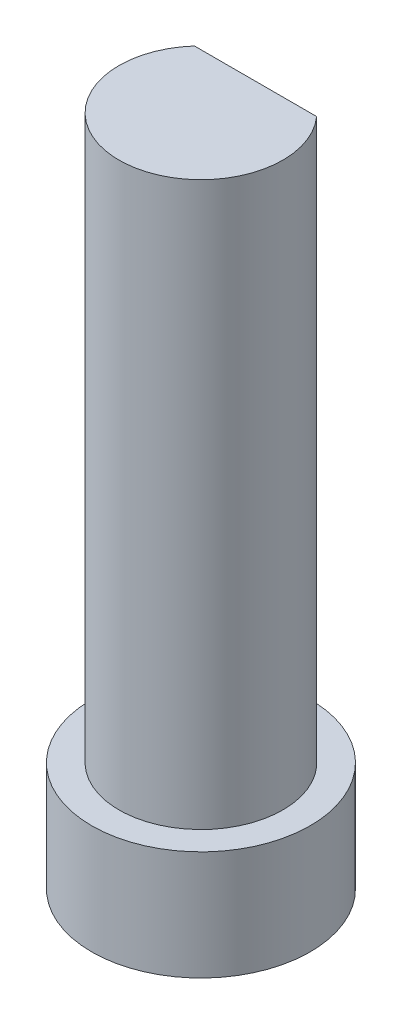
from build123d import *

# Parameters (mm, degrees)
CROQUIS1_R              = 2
SALIENTE_EXTRUIR1_DEPTH = 2
CROQUIS2_R              = 0.2
CORTAR_EXTRUIR1_DEPTH   = 2
CROQUIS3_R              = 1.5
SALIENTE_EXTRUIR2_DEPTH = 10.3
CORTAR_EXTRUIR2_DEPTH   = 10.3


with BuildPart() as part:
    # Croquis1 → Saliente-Extruir1 (new body)
    with BuildSketch(Plane(origin=(0, 0, 0), x_dir=(1, 0, 0), z_dir=(0, 1, 0))):
        Circle(CROQUIS1_R)
    extrude(amount=SALIENTE_EXTRUIR1_DEPTH)

    # Croquis2 → Cortar-Extruir1 (cut)
    with BuildSketch(Plane.XZ):
        Circle(CROQUIS2_R)
    extrude(amount=-CORTAR_EXTRUIR1_DEPTH, mode=Mode.SUBTRACT)


with BuildPart() as body_2:
    # Croquis3 → Saliente-Extruir2 (new body)
    with BuildSketch(Plane(origin=(0, 2, 0), x_dir=(1, 0, 0), z_dir=(0, 1, 0))):
        Circle(CROQUIS3_R)
    extrude(amount=SALIENTE_EXTRUIR2_DEPTH)

    # Croquis5 → Cortar-Extruir2 (cut)
    with BuildSketch(Plane(origin=(0, 12.3, 0), x_dir=(1, 0, 0), z_dir=(0, 1, 0))):
        with BuildLine():
            Line((0, 1), (1.118033989, 1))
            ThreePointArc((1.118033989, 1), (0, 1.5), (-1.118033989, 1))
            Line((-1.118033989, 1), (0, 1))
        make_face()
    extrude(amount=-CORTAR_EXTRUIR2_DEPTH, mode=Mode.SUBTRACT)


solid = Compound([part.part, body_2.part])
